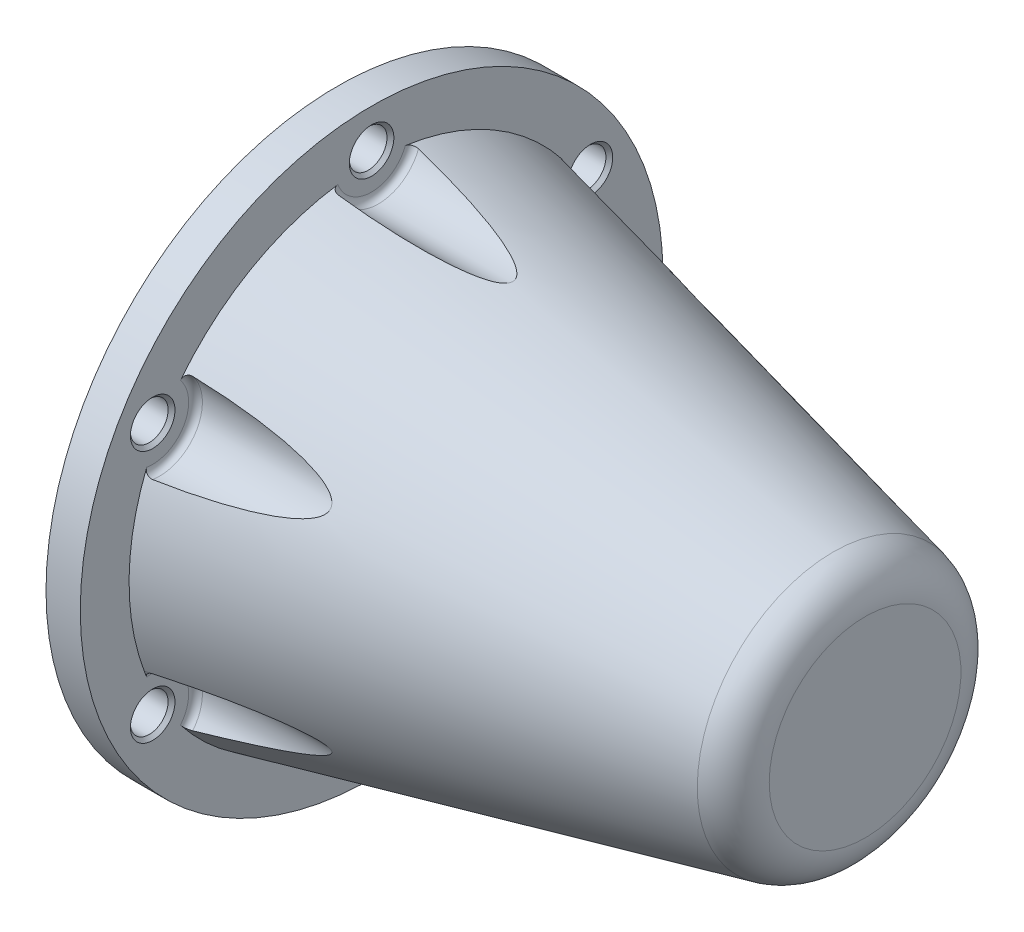
from build123d import *

# Parameters (mm, degrees)
SZKIC2_R                   = 12.5
WYTNIJ_WYCI_GNI_CIE1_DEPTH = 134
SZYK_KO_OWY1_COUNT         = 6
ZAOKR_GLENIE1_R            = 12
ZAOKR_GLENIE2_R            = 2
ZAOKR_GLENIE3_R            = 2
SFAZOWANIE1_SIZE           = 1


with BuildPart() as part:
    # Szkic1 → Obrót1 (revolve)
    with BuildSketch(Plane.XY, mode=Mode.PRIVATE) as obr_t1_sk:
        Polygon((154, 0), (154, 37.518021556), (10, 70.763041078), (10, 85), (0, 85), (0, 60.5), (10, 60.5), (144, 29.563662389), (144, 0), align=None)
    revolve(obr_t1_sk.sketch.rotate(Axis((0, 0, 0), (1, 0, 0)), 90), axis=Axis((0, 0, 0), (1, 0, 0)))  # turned: the seam where the file's is

    # Szkic2 → Wytnij-wyciągnięcie1 (cut)
    with BuildSketch(Plane(origin=(10, 0, 0), x_dir=(0, 0, -1), z_dir=(1, 0, 0))):
        with Locations((0, 73.75)):
            Circle(SZKIC2_R)
    wytnij_wyci_gni_cie1 = extrude(amount=WYTNIJ_WYCI_GNI_CIE1_DEPTH, mode=Mode.SUBTRACT)

    # Szkic3 → Otwór pod śrubę M101 (revolve, cut)
    with BuildSketch(Plane(origin=(10, 73.75, 0), x_dir=(0, 0, -1), z_dir=(0, 1, 0))):
        Polygon((0, 0), (0, 10), (6.5, 10), (5.5, 9), (5.5, 1), (6.5, 0), align=None)
    otw_r_pod_rub_m101 = revolve(axis=Axis((16.35, 73.75, 0), (-1, 0, 0)), mode=Mode.SUBTRACT)

    # Szyk kołowy1: Wytnij-wyciągnięcie1, Otwór pod śrubę M101 ×6 about axis
    szyk_ko_owy1_axis = Axis((0, 0, 0), (1, 0, 0))
    add([wytnij_wyci_gni_cie1.rotate(szyk_ko_owy1_axis, i * 360 / SZYK_KO_OWY1_COUNT) for i in range(1, SZYK_KO_OWY1_COUNT)], mode=Mode.SUBTRACT)
    add([otw_r_pod_rub_m101.rotate(szyk_ko_owy1_axis, i * 360 / SZYK_KO_OWY1_COUNT) for i in range(1, SZYK_KO_OWY1_COUNT)], mode=Mode.SUBTRACT)

    # Zaokrąglenie1
    zaokr_glenie1_edges = [part.edges().sort_by_distance(p)[0] for p in [
        (154, 0, -37.518021556),
    ]]
    fillet(zaokr_glenie1_edges, radius=ZAOKR_GLENIE1_R)

    # Zaokrąglenie2
    zaokr_glenie2_edges = [part.edges().sort_by_distance(p)[0] for p in [
        (10, -30.625, -53.044055982),
        (10, -61.25, 0),
        (10, -30.625, 53.044055982),
        (10, 30.625, 53.044055982),
        (10, 61.25, 0),
        (10, 30.625, -53.044055982),
    ]]
    fillet(zaokr_glenie2_edges, radius=ZAOKR_GLENIE2_R)

    # Zaokrąglenie3
    zaokr_glenie3_edges = [part.edges().sort_by_distance(p)[0] for p in [
        (144, 0, -29.563662389),
    ]]
    fillet(zaokr_glenie3_edges, radius=ZAOKR_GLENIE3_R)

    # Sfazowanie1
    sfazowanie1_edges = [part.edges().sort_by_distance(p)[0] for p in [
        (0, 0, -60.5),
    ]]
    chamfer(sfazowanie1_edges, length=SFAZOWANIE1_SIZE)


solid = part.part
